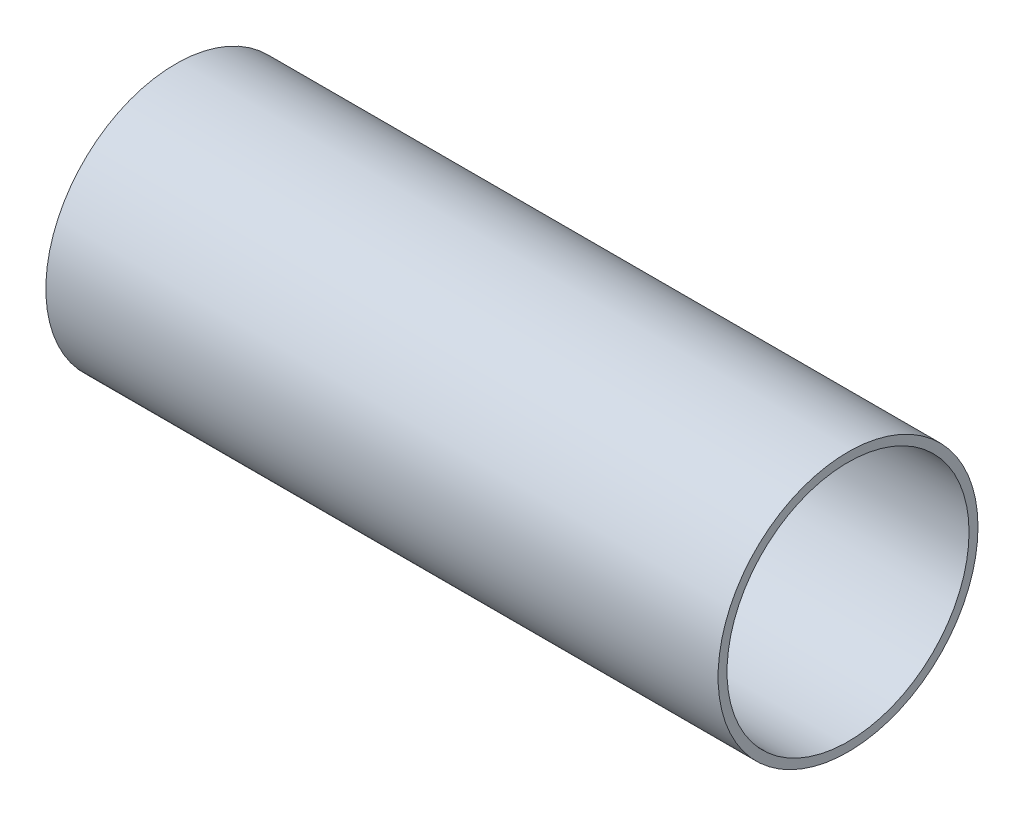
from build123d import *

# Parameters (mm, degrees)
SKETCH1_R           = 29
SKETCH1_R_2         = 27
BOSS_EXTRUDE1_DEPTH = 150


with BuildPart() as part:
    # Sketch1 → Boss-Extrude1 (new body)
    with BuildSketch(Plane(origin=(0, 0, 0), x_dir=(0, 0, -1), z_dir=(1, 0, 0))):
        Circle(SKETCH1_R)
        Circle(SKETCH1_R_2, mode=Mode.SUBTRACT)
    extrude(amount=BOSS_EXTRUDE1_DEPTH)


solid = part.part
